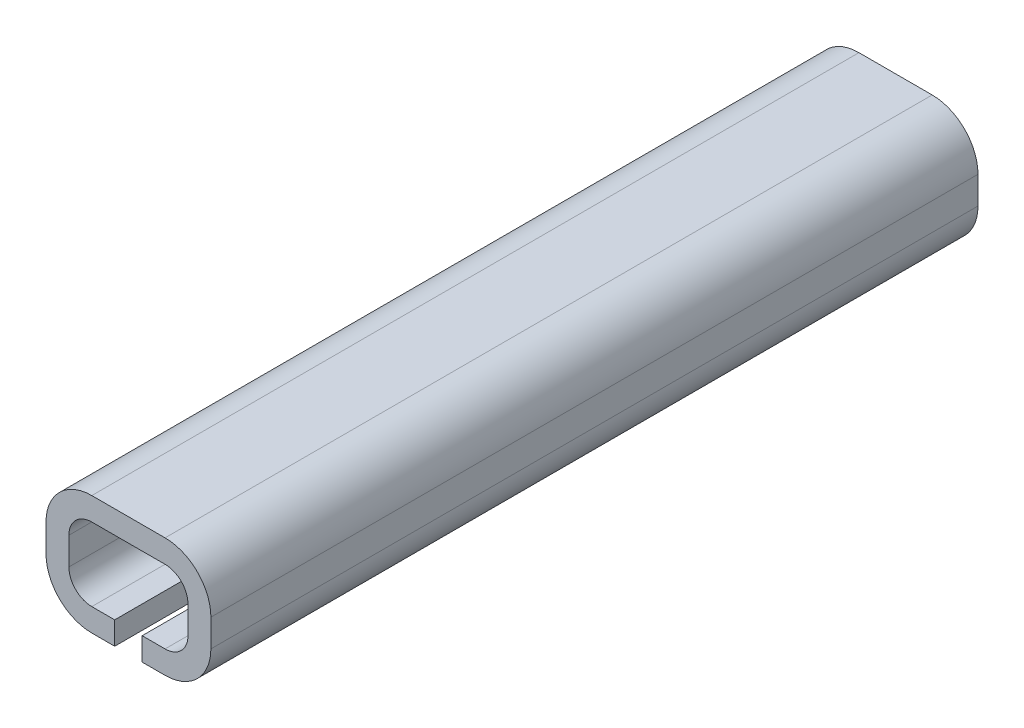
from build123d import *

# Parameters (mm, degrees)
BOSS_EXTRU_2_DEPTH      = 10
BOSS_EXTRU_4_DEPTH      = 6.75
ESQUISSE5_W             = 1.2
ESQUISSE5_H             = 10
ENL_V_MAT_EXTRU_1_DEPTH = 1


with BuildPart() as part:
    # Esquisse1 → Boss.-Extru.2 (new body)
    with BuildSketch(Plane.XY):
        with BuildLine():
            Line((3.6, -0.6), (3.6, 0.6))
            ThreePointArc((3.6, 0.6), (3.014213562, 2.014213562), (1.6, 2.6))
            Line((1.6, 2.6), (0.167949192, 2.6))
            Line((0.167949192, 2.6), (-1.6, 2.6))
            ThreePointArc((-1.6, 2.6), (-3.014213562, 2.014213562), (-3.6, 0.6))
            Line((-3.6, 0.6), (-3.6, -0.6))
            ThreePointArc((-3.6, -0.6), (-3.014213562, -2.014213562), (-1.6, -2.6))
            Line((-1.6, -2.6), (1.6, -2.6))
            ThreePointArc((1.6, -2.6), (3.014213562, -2.014213562), (3.6, -0.6))
        make_face()
        with BuildLine():
            ThreePointArc((1.6, 1.6), (2.307106781, 1.307106781), (2.6, 0.6))
            Line((2.6, 0.6), (2.6, -0.6))
            ThreePointArc((2.6, -0.6), (2.307106781, -1.307106781), (1.6, -1.6))
            Line((1.6, -1.6), (-1.6, -1.6))
            ThreePointArc((-1.6, -1.6), (-2.307106781, -1.307106781), (-2.6, -0.6))
            Line((-2.6, -0.6), (-2.6, 0.6))
            ThreePointArc((-2.6, 0.6), (-2.307106781, 1.307106781), (-1.6, 1.6))
            Line((-1.6, 1.6), (1.6, 1.6))
        make_face(mode=Mode.SUBTRACT)
    boss_extru_2 = extrude(amount=BOSS_EXTRU_2_DEPTH)

    # Esquisse7 → Boss.-Extru.4 (add)
    with BuildSketch(Plane(origin=(0, 0, 0), x_dir=(-1, 0, 0), z_dir=(0, 0, -1))):
        with BuildLine():
            Line((-3.6, 0.6), (-3.6, -0.6))
            ThreePointArc((-3.6, -0.6), (-3.014213562, -2.014213562), (-1.6, -2.6))
            Line((-1.6, -2.6), (1.6, -2.6))
            ThreePointArc((1.6, -2.6), (3.014213562, -2.014213562), (3.6, -0.6))
            Line((3.6, -0.6), (3.6, 0.6))
            ThreePointArc((3.6, 0.6), (3.014213562, 2.014213562), (1.6, 2.6))
            Line((1.6, 2.6), (-1.6, 2.6))
            ThreePointArc((-1.6, 2.6), (-3.014213562, 2.014213562), (-3.6, 0.6))
        make_face()
    boss_extru_4 = extrude(amount=BOSS_EXTRU_4_DEPTH)

    # Symétrie1: Boss.-Extru.2, Boss.-Extru.4 across plane
    add(boss_extru_2.mirror(Plane(origin=(1.6, 0.6, -6.75), x_dir=(1, 0, 0), z_dir=(0, 0, -1))))
    add(boss_extru_4.mirror(Plane(origin=(1.6, 0.6, -6.75), x_dir=(1, 0, 0), z_dir=(0, 0, -1))))

    # Esquisse5 → Enlèv. mat.-Extru.1 (cut)
    with BuildSketch(Plane.XZ.offset(2.6)):
        with Locations((0, -18.5)):
            Rectangle(ESQUISSE5_W, ESQUISSE5_H)
        with Locations((0, 5)):
            Rectangle(ESQUISSE5_W, ESQUISSE5_H)
    extrude(amount=-ENL_V_MAT_EXTRU_1_DEPTH, mode=Mode.SUBTRACT)


solid = part.part
